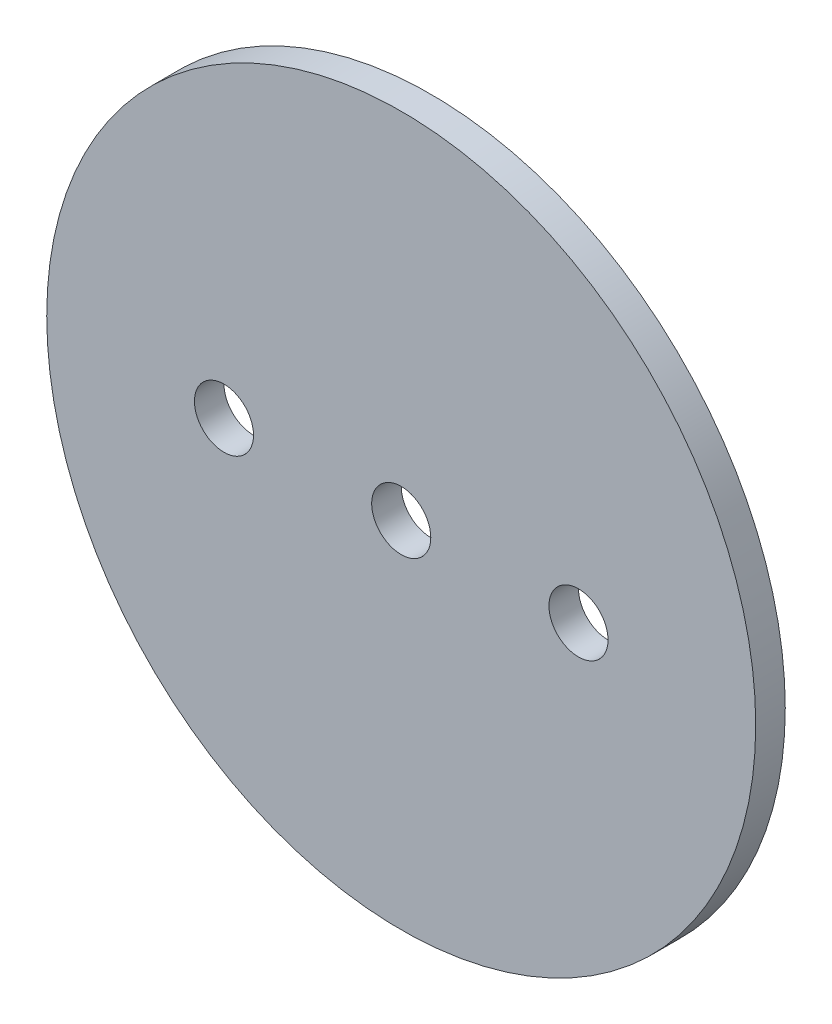
from build123d import *

# Parameters (mm, degrees)
SKETCH1_R                   = 38.1
BOSS_EXTRUDE1_DEPTH         = 1.5875
F_1_4_0_25_DIAMETER_HOLE1_D = 6.35


with BuildPart() as part:
    # Sketch1 → Boss-Extrude1 (new body, symmetric)
    with BuildSketch(Plane.XY):
        Circle(SKETCH1_R)
    extrude(amount=BOSS_EXTRUDE1_DEPTH, both=True)

    # 1/4 (0.25) Diameter Hole1 (through all)
    with Locations(Plane.XY.offset(1.5875)):
        with Locations((-19.05, 0), (0, 0), (19.05, 0)):
            Hole(F_1_4_0_25_DIAMETER_HOLE1_D / 2)


solid = part.part
